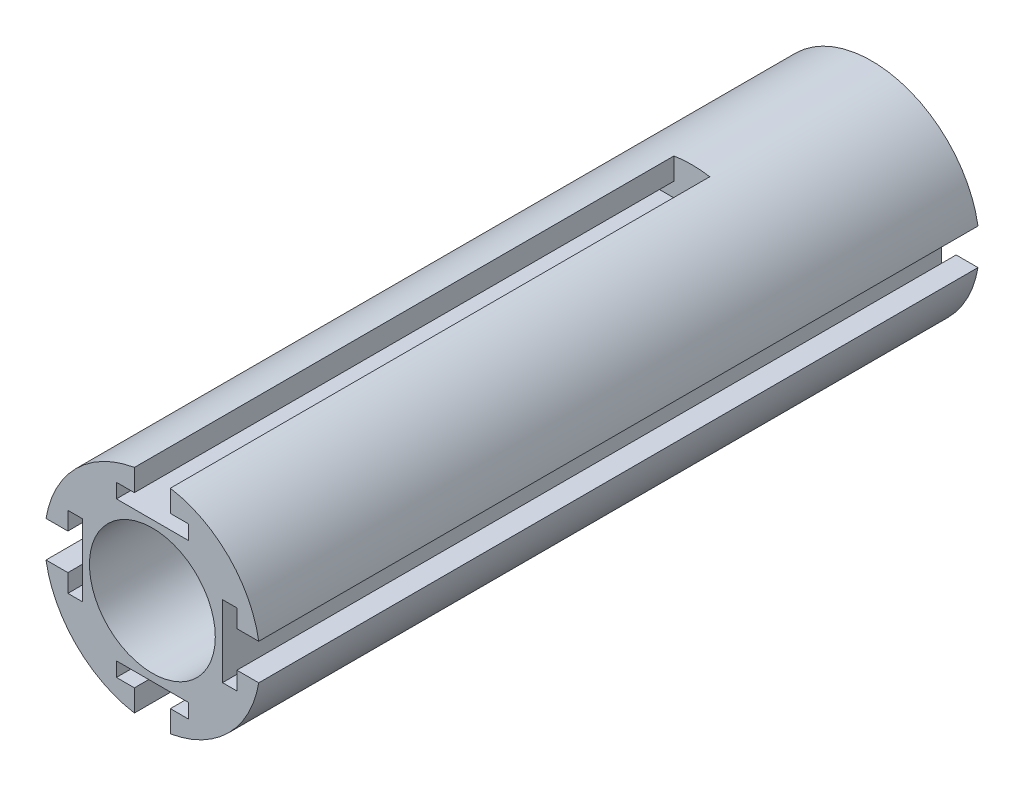
from build123d import *

# Parameters (mm, degrees)
SKETCH1_R           = 30
SKETCH1_R_2         = 17.5
BOSS_EXTRUDE1_DEPTH = 200
CUT_EXTRUDE1_START  = -150
CUT_EXTRUDE1_DEPTH  = 150
CUT_EXTRUDE2_START  = -50
CUT_EXTRUDE2_DEPTH  = 50
CUT_EXTRUDE3_DEPTH  = 205.450483003


with BuildPart() as part:
    # Sketch1 → Boss-Extrude1 (new body)
    with BuildSketch(Plane.XY):
        Circle(SKETCH1_R)
        Circle(SKETCH1_R_2, mode=Mode.SUBTRACT)
    extrude(amount=BOSS_EXTRUDE1_DEPTH)

    # Sketch2 → Cut-Extrude1 (cut)
    with BuildSketch(Plane.XY.offset(200).offset(CUT_EXTRUDE1_START)):
        with BuildLine():
            Line((-10, 23.5), (-10, 19.5))
            Line((-10, 19.5), (10, 19.5))
            Line((10, 19.5), (10, 23.5))
            Line((10, 23.5), (5, 23.5))
            Line((5, 23.5), (5, 29.580398915))
            ThreePointArc((5, 29.580398915), (0, 30), (-5, 29.580398915))
            Line((-5, 29.580398915), (-5, 23.5))
            Line((-5, 23.5), (-10, 23.5))
        make_face()
    extrude(amount=CUT_EXTRUDE1_DEPTH, mode=Mode.SUBTRACT)

    # Sketch2_3 → Cut-Extrude2 (cut)
    with BuildSketch(Plane.XY.offset(200).offset(CUT_EXTRUDE2_START)):
        with BuildLine():
            Line((-5, -23.5), (-5, -29.580398915))
            ThreePointArc((-5, -29.580398915), (0, -30), (5, -29.580398915))
            Line((5, -29.580398915), (5, -23.5))
            Line((5, -23.5), (10, -23.5))
            Line((10, -23.5), (10, -19.5))
            Line((10, -19.5), (-10, -19.5))
            Line((-10, -19.5), (-10, -23.5))
            Line((-10, -23.5), (-5, -23.5))
        make_face()
    cut_extrude2 = extrude(amount=CUT_EXTRUDE2_DEPTH, mode=Mode.SUBTRACT)

    # Mirror1: Cut-Extrude2 across plane
    add(cut_extrude2.mirror(Plane.XY.offset(100)), mode=Mode.SUBTRACT)

    # Sketch2_5 → Cut-Extrude3 (cut, through all)
    with BuildSketch(Plane.XY.offset(200)):
        with BuildLine():
            Line((-23.5, 5), (-29.580398915, 5))
            ThreePointArc((-29.580398915, 5), (-30, 0), (-29.580398915, -5))
            Line((-29.580398915, -5), (-23.5, -5))
            Line((-23.5, -5), (-23.5, -10))
            Line((-23.5, -10), (-19.5, -10))
            Line((-19.5, -10), (-19.5, 10))
            Line((-19.5, 10), (-23.5, 10))
            Line((-23.5, 10), (-23.5, 5))
        make_face()
        with BuildLine():
            ThreePointArc((29.580398915, -5), (30, 0), (29.580398915, 5))
            Line((29.580398915, 5), (23.5, 5))
            Line((23.5, 5), (23.5, 10))
            Line((23.5, 10), (19.5, 10))
            Line((19.5, 10), (19.5, -10))
            Line((19.5, -10), (23.5, -10))
            Line((23.5, -10), (23.5, -5))
            Line((23.5, -5), (29.580398915, -5))
        make_face()
    extrude(amount=-CUT_EXTRUDE3_DEPTH, mode=Mode.SUBTRACT)


solid = part.part
